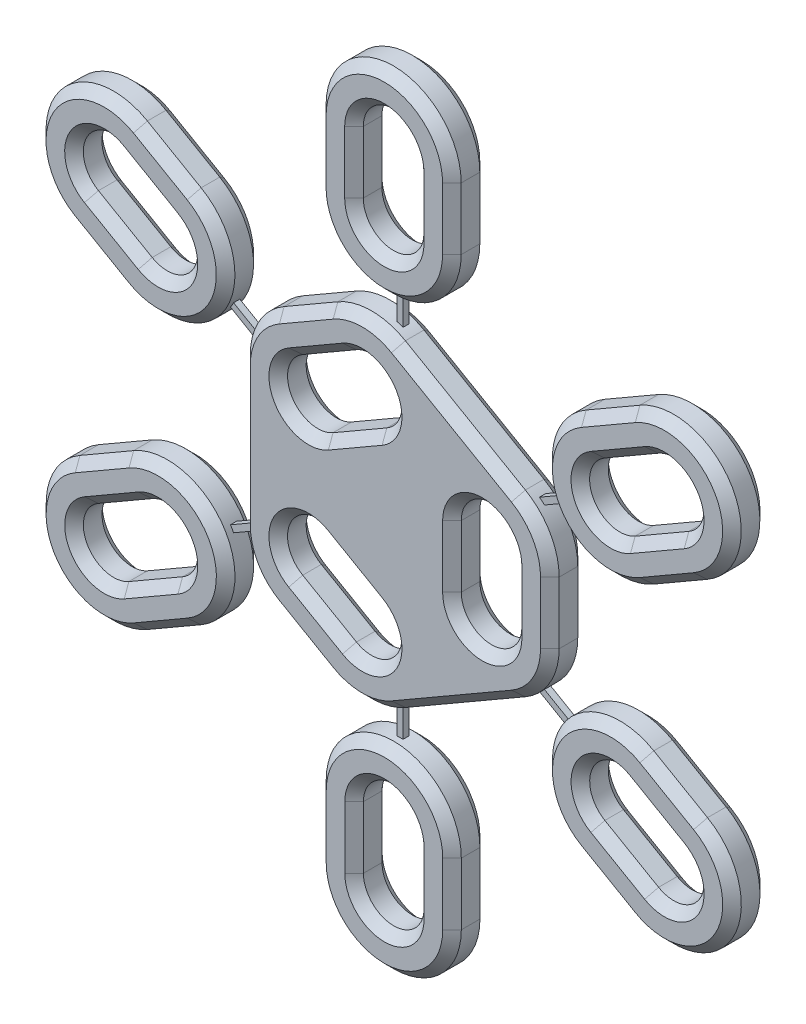
from build123d import *

# Parameters (mm, degrees)
SKETCH1_R               = 4.4
SKETCH1_R_2             = 2
BOSS_EXTRUDE1_DEPTH     = 2.4
CHAMFER1_SIZE           = 0.4
BOSS_EXTRUDE2_DEPTH     = 2.4
BOSS_EXTRUDE2_2_DEPTH   = 2.4
BOSS_EXTRUDE2_3_DEPTH   = 2.4
BOSS_EXTRUDE2_4_DEPTH   = 2.4
BOSS_EXTRUDE2_5_DEPTH   = 2.4
BOSS_EXTRUDE2_6_DEPTH   = 2.4
BOSS_EXTRUDE2_7_DEPTH   = 2.4
BOSS_EXTRUDE2_8_DEPTH   = 2.4
CHAMFER2_SIZE           = 0.6
CHAMFER3_SIZE           = 0.6
CHAMFER4_SIZE           = 0.6
CHAMFER5_SIZE           = 0.6
CHAMFER6_SIZE           = 0.6
CHAMFER7_SIZE           = 0.6
CHAMFER8_SIZE           = 0.6
CHAMFER9_SIZE           = 0.6
BOSS_EXTRUDE3_START     = -1.2
BOSS_EXTRUDE3_DEPTH     = 0.2
CIRPATTERN1_COUNT       = 6
CUT_EXTRUDE1_DEPTH      = 1
CUT_EXTRUDE1_DEPTH_BACK = 3.4


with BuildPart() as part:
    # Sketch1 → Boss-Extrude1 (new body)
    with BuildSketch(Plane.XY):
        Circle(SKETCH1_R)
        Circle(SKETCH1_R_2, mode=Mode.SUBTRACT)
    extrude(amount=BOSS_EXTRUDE1_DEPTH)

    # Chamfer1
    chamfer1_edges = [part.edges().sort_by_distance(p)[0] for p in [
        (-4.4, 0, 0),
        (-4.4, 0, 2.4),
        (-2, 0, 0),
        (-2, 0, 2.4),
    ]]
    chamfer(chamfer1_edges, length=CHAMFER1_SIZE)


with BuildPart() as body_2:
    # Sketch2 → Boss-Extrude2 (new body)
    with BuildSketch(Plane(origin=(0, 0, 0), x_dir=(-1, 0, 0), z_dir=(0, 0, -1))):
        with BuildLine():
            Line((9.243212733, 4.465626555), (9.243212733, -4.465626555))
            ThreePointArc((9.243212733, -4.465626555), (8.659675532, -6.643417036), (7.065422252, -8.237670317))
            Line((7.065422252, -8.237670317), (3.601320636, -10.237670317))
            ThreePointArc((3.601320636, -10.237670317), (1.423530155, -10.821207517), (-0.754260326, -10.237670317))
            Line((-0.754260326, -10.237670317), (-8.488952407, -5.772043762))
            ThreePointArc((-8.488952407, -5.772043762), (-10.083205687, -4.177790481), (-10.666742888, -2))
            Line((-10.666742888, -2), (-10.666742888, 2))
            ThreePointArc((-10.666742888, 2), (-10.083205687, 4.177790481), (-8.488952407, 5.772043762))
            Line((-8.488952407, 5.772043762), (-0.754260326, 10.237670317))
            ThreePointArc((-0.754260326, 10.237670317), (1.423530155, 10.821207517), (3.601320636, 10.237670317))
            Line((3.601320636, 10.237670317), (7.065422252, 8.237670317))
            ThreePointArc((7.065422252, 8.237670317), (8.659675532, 6.643417036), (9.243212733, 4.465626555))
        make_face()
        with BuildLine():
            Line((-4.355580963, 2), (-4.355580963, -2))
            ThreePointArc((-4.355580963, -2), (-6.311161925, -3.955580963), (-8.266742888, -2))
            Line((-8.266742888, -2), (-8.266742888, 2))
            ThreePointArc((-8.266742888, 2), (-6.311161925, 3.955580963), (-4.355580963, 2))
        make_face(mode=Mode.SUBTRACT)
        with BuildLine():
            Line((3.909841289, 2.772043762), (0.445739674, 4.772043762))
            ThreePointArc((0.445739674, 4.772043762), (-0.270052638, 7.443417036), (2.401320636, 8.159209348))
            Line((2.401320636, 8.159209348), (5.865422252, 6.159209348))
            ThreePointArc((5.865422252, 6.159209348), (6.581214563, 3.487836073), (3.909841289, 2.772043762))
        make_face(mode=Mode.SUBTRACT)
        with BuildLine():
            Line((0.445739674, -4.772043762), (3.909841289, -2.772043762))
            ThreePointArc((3.909841289, -2.772043762), (6.581214563, -3.487836073), (5.865422252, -6.159209348))
            Line((5.865422252, -6.159209348), (2.401320636, -8.159209348))
            ThreePointArc((2.401320636, -8.159209348), (-0.270052638, -7.443417036), (0.445739674, -4.772043762))
        make_face(mode=Mode.SUBTRACT)
    extrude(amount=BOSS_EXTRUDE2_DEPTH)

    # Chamfer3
    chamfer3_edges = [body_2.edges().sort_by_distance(p)[0] for p in [
        (-6.581214563, 3.487836073, 0),
        (-4.133371444, 7.159209348, 0),
        (0.270052638, 7.443417036, 0),
        (-2.177790481, 3.772043762, 0),
        (-6.581214563, 3.487836073, -2.4),
        (-4.133371444, 7.159209348, -2.4),
        (0.270052638, 7.443417036, -2.4),
        (-2.177790481, 3.772043762, -2.4),
        (0.270052638, -7.443417036, 0),
        (-4.133371444, -7.159209348, 0),
        (-6.581214563, -3.487836073, 0),
        (-2.177790481, -3.772043762, 0),
        (0.270052638, -7.443417036, -2.4),
        (-4.133371444, -7.159209348, -2.4),
        (-6.581214563, -3.487836073, -2.4),
        (-2.177790481, -3.772043762, -2.4),
        (6.311161925, 3.955580963, 0),
        (8.266742888, 0, 0),
        (6.311161925, -3.955580963, 0),
        (4.355580963, 0, 0),
        (6.311161925, 3.955580963, -2.4),
        (8.266742888, 0, -2.4),
        (6.311161925, -3.955580963, -2.4),
        (4.355580963, 0, -2.4),
        (10.083205687, -4.177790481, 0),
        (4.621606366, -8.004857039, 0),
        (-1.423530155, -10.821207517, 0),
        (-5.333371444, -9.237670317, 0),
        (-8.659675532, -6.643417036, 0),
        (-9.243212733, 0, 0),
        (-8.659675532, 6.643417036, 0),
        (-5.333371444, 9.237670317, 0),
        (-1.423530155, 10.821207517, 0),
        (4.621606366, 8.004857039, 0),
        (10.083205687, 4.177790481, 0),
        (10.666742888, 0, 0),
        (10.083205687, -4.177790481, -2.4),
        (4.621606366, -8.004857039, -2.4),
        (-1.423530155, -10.821207517, -2.4),
        (-5.333371444, -9.237670317, -2.4),
        (-8.659675532, -6.643417036, -2.4),
        (-9.243212733, 0, -2.4),
        (-8.659675532, 6.643417036, -2.4),
        (-5.333371444, 9.237670317, -2.4),
        (-1.423530155, 10.821207517, -2.4),
        (4.621606366, 8.004857039, -2.4),
        (10.083205687, 4.177790481, -2.4),
        (10.666742888, 0, -2.4),
    ]]
    chamfer(chamfer3_edges, length=CHAMFER3_SIZE)


with BuildPart() as body_3:
    # Sketch2 → Boss-Extrude2 2 (new body)
    with BuildSketch(Plane(origin=(0, 0, 0), x_dir=(-1, 0, 0), z_dir=(0, 0, -1))):
        with BuildLine():
            Line((4.351336317, -16.847070519), (4.351336317, -20.847070519))
            ThreePointArc((4.351336317, -20.847070519), (-0.004244646, -25.202651481), (-4.359825609, -20.847070519))
            Line((-4.359825609, -20.847070519), (-4.359825609, -16.847070519))
            ThreePointArc((-4.359825609, -16.847070519), (-0.004244646, -12.491489556), (4.351336317, -16.847070519))
        make_face()
        with BuildLine():
            Line((1.951336317, -16.847070519), (1.951336317, -20.847070519))
            ThreePointArc((1.951336317, -20.847070519), (-0.004244646, -22.802651481), (-1.959825609, -20.847070519))
            Line((-1.959825609, -20.847070519), (-1.959825609, -16.847070519))
            ThreePointArc((-1.959825609, -16.847070519), (-0.004244646, -14.891489556), (1.951336317, -16.847070519))
        make_face(mode=Mode.SUBTRACT)
    extrude(amount=BOSS_EXTRUDE2_2_DEPTH)

    # Chamfer6
    chamfer6_edges = [body_3.edges().sort_by_distance(p)[0] for p in [
        (0.004244646, -25.202651481, -2.4),
        (-4.351336317, -18.847070519, -2.4),
        (0.004244646, -14.891489556, 0),
        (1.959825609, -18.847070519, 0),
        (0.004244646, -22.802651481, 0),
        (-1.951336317, -18.847070519, -2.4),
        (0.004244646, -14.891489556, -2.4),
        (1.959825609, -18.847070519, -2.4),
        (0.004244646, -22.802651481, -2.4),
        (-1.951336317, -18.847070519, 0),
        (0.004244646, -12.491489556, -2.4),
        (-4.351336317, -18.847070519, 0),
        (0.004244646, -25.202651481, 0),
        (4.359825609, -18.847070519, 0),
        (0.004244646, -12.491489556, 0),
        (4.359825609, -18.847070519, -2.4),
    ]]
    chamfer(chamfer6_edges, length=CHAMFER6_SIZE)

    # Sketch3 → Boss-Extrude3 (add, symmetric)
    with BuildSketch(Plane(origin=(0, 0, -2.4), x_dir=(-1, 0, 0), z_dir=(0, 0, -1)).offset(BOSS_EXTRUDE3_START)):
        Polygon((0, -13.635046373), (0.2, -13.635046373), (0.2, -0.714557535), (0, 0), (-0.2, -0.714557535), (-0.2, -13.521615486), (0, -13.521615486), align=None)
    extrude(amount=BOSS_EXTRUDE3_DEPTH, both=True)


with BuildPart() as body_4:
    # Sketch2 → Boss-Extrude2 3 (new body)
    with BuildSketch(Plane(origin=(0, 0, 0), x_dir=(-1, 0, 0), z_dir=(0, 0, -1))):
        with BuildLine():
            Line((-10.458556301, -13.905988383), (-13.585882231, -16.39994759))
            ThreePointArc((-13.585882231, -16.39994759), (-19.706872863, -15.71027758), (-19.017202854, -9.589286948))
            Line((-19.017202854, -9.589286948), (-15.889876924, -7.095327741))
            ThreePointArc((-15.889876924, -7.095327741), (-9.768886291, -7.78499775), (-10.458556301, -13.905988383))
        make_face()
        with BuildLine():
            Line((-11.954931825, -12.029592825), (-15.082257755, -14.523552032))
            ThreePointArc((-15.082257755, -14.523552032), (-17.830477305, -14.213902056), (-17.520827329, -11.465682506))
            Line((-17.520827329, -11.465682506), (-14.393501399, -8.971723299))
            ThreePointArc((-14.393501399, -8.971723299), (-11.645281849, -9.281373275), (-11.954931825, -12.029592825))
        make_face(mode=Mode.SUBTRACT)
    extrude(amount=BOSS_EXTRUDE2_3_DEPTH)

    # Chamfer7
    chamfer7_edges = [body_4.edges().sort_by_distance(p)[0] for p in [
        (11.645281849, -9.281373275, 0),
        (15.957164364, -10.218702902, 0),
        (17.830477305, -14.213902056, 0),
        (13.51859479, -13.276572428, 0),
        (11.645281849, -9.281373275, -2.4),
        (15.957164364, -10.218702902, -2.4),
        (17.830477305, -14.213902056, -2.4),
        (13.51859479, -13.276572428, -2.4),
        (9.768886291, -7.78499775, 0),
        (17.453539889, -8.342307344, 0),
        (19.706872863, -15.71027758, 0),
        (12.022219266, -15.152967986, 0),
        (9.768886291, -7.78499775, -2.4),
        (17.453539889, -8.342307344, -2.4),
        (19.706872863, -15.71027758, -2.4),
        (12.022219266, -15.152967986, -2.4),
    ]]
    chamfer(chamfer7_edges, length=CHAMFER7_SIZE)


with BuildPart() as body_5:
    # Sketch2 → Boss-Extrude2 4 (new body)
    with BuildSketch(Plane(origin=(0, 0, 0), x_dir=(-1, 0, 0), z_dir=(0, 0, -1))):
        with BuildLine():
            Line((-17.392942708, -0.493413364), (-21.292654357, 0.396670372))
            ThreePointArc((-21.292654357, 0.396670372), (-24.569823868, 5.61225577), (-19.35423847, 8.88942528))
            Line((-19.35423847, 8.88942528), (-15.454526821, 7.999341544))
            ThreePointArc((-15.454526821, 7.999341544), (-12.17735731, 2.783756146), (-17.392942708, -0.493413364))
        make_face()
        with BuildLine():
            Line((-16.858892467, 1.846413625), (-20.758604116, 2.736497361))
            ThreePointArc((-20.758604116, 2.736497361), (-22.229996878, 5.078205528), (-19.888288711, 6.549598291))
            Line((-19.888288711, 6.549598291), (-15.988577062, 5.659514555))
            ThreePointArc((-15.988577062, 5.659514555), (-14.5171843, 3.317806388), (-16.858892467, 1.846413625))
        make_face(mode=Mode.SUBTRACT)
    extrude(amount=BOSS_EXTRUDE2_4_DEPTH)

    # Chamfer8
    chamfer8_edges = [body_5.edges().sort_by_distance(p)[0] for p in [
        (14.5171843, 3.317806388, 0),
        (17.938432887, 6.104556423, 0),
        (22.229996878, 5.078205528, 0),
        (18.808748291, 2.291455493, 0),
        (14.5171843, 3.317806388, -2.4),
        (17.938432887, 6.104556423, -2.4),
        (22.229996878, 5.078205528, -2.4),
        (18.808748291, 2.291455493, -2.4),
        (12.17735731, 2.783756146, 0),
        (17.404382645, 8.444383412, 0),
        (24.569823868, 5.61225577, 0),
        (19.342798533, -0.048371496, 0),
        (12.17735731, 2.783756146, -2.4),
        (17.404382645, 8.444383412, -2.4),
        (24.569823868, 5.61225577, -2.4),
        (19.342798533, -0.048371496, -2.4),
    ]]
    chamfer(chamfer8_edges, length=CHAMFER8_SIZE)


with BuildPart() as body_6:
    # Sketch2 → Boss-Extrude2 5 (new body)
    with BuildSketch(Plane(origin=(0, 0, 0), x_dir=(-1, 0, 0), z_dir=(0, 0, -1))):
        with BuildLine():
            Line((-11.230088505, 13.290711982), (-12.965623461, 16.894587453))
            ThreePointArc((-12.965623461, 16.894587453), (-10.931196366, 22.708646056), (-5.117137763, 20.674218961))
            Line((-5.117137763, 20.674218961), (-3.381602807, 17.07034349))
            ThreePointArc((-3.381602807, 17.07034349), (-5.416029902, 11.256284887), (-11.230088505, 13.290711982))
        make_face()
        with BuildLine():
            Line((-9.067763222, 14.332032955), (-10.803298178, 17.935908427))
            ThreePointArc((-10.803298178, 17.935908427), (-9.889875393, 20.546320773), (-7.279463046, 19.632897987))
            Line((-7.279463046, 19.632897987), (-5.54392809, 16.029022516))
            ThreePointArc((-5.54392809, 16.029022516), (-6.457350876, 13.41861017), (-9.067763222, 14.332032955))
        make_face(mode=Mode.SUBTRACT)
    extrude(amount=BOSS_EXTRUDE2_5_DEPTH)

    # Chamfer9
    chamfer9_edges = [body_6.edges().sort_by_distance(p)[0] for p in [
        (6.457350876, 13.41861017, 0),
        (6.411695568, 17.830960252, 0),
        (9.889875393, 20.546320773, 0),
        (9.9355307, 16.133970691, 0),
        (6.457350876, 13.41861017, -2.4),
        (6.411695568, 17.830960252, -2.4),
        (9.889875393, 20.546320773, -2.4),
        (9.9355307, 16.133970691, -2.4),
        (5.416029902, 11.256284887, 0),
        (4.249370285, 18.872281226, 0),
        (10.931196366, 22.708646056, 0),
        (12.097855983, 15.092649717, 0),
        (5.416029902, 11.256284887, -2.4),
        (4.249370285, 18.872281226, -2.4),
        (10.931196366, 22.708646056, -2.4),
        (12.097855983, 15.092649717, -2.4),
    ]]
    chamfer(chamfer9_edges, length=CHAMFER9_SIZE)


with BuildPart() as body_7:
    # Sketch2 → Boss-Extrude2 6 (new body)
    with BuildSketch(Plane(origin=(0, 0, 0), x_dir=(-1, 0, 0), z_dir=(0, 0, -1))):
        with BuildLine():
            Line((3.389251395, 17.066660124), (5.124786351, 20.670535595))
            ThreePointArc((5.124786351, 20.670535595), (10.938844954, 22.70496269), (12.973272049, 16.890904087))
            Line((12.973272049, 16.890904087), (11.237737093, 13.287028616))
            ThreePointArc((11.237737093, 13.287028616), (5.42367849, 11.252601521), (3.389251395, 17.066660124))
        make_face()
        with BuildLine():
            Line((5.551576678, 16.02533915), (7.287111634, 19.629214622))
            ThreePointArc((7.287111634, 19.629214622), (9.897523981, 20.542637407), (10.810946766, 17.932225061))
            Line((10.810946766, 17.932225061), (9.07541181, 14.32834959))
            ThreePointArc((9.07541181, 14.32834959), (6.464999464, 13.414926804), (5.551576678, 16.02533915))
        make_face(mode=Mode.SUBTRACT)
    extrude(amount=BOSS_EXTRUDE2_6_DEPTH)

    # Chamfer4
    chamfer4_edges = [body_7.edges().sort_by_distance(p)[0] for p in [
        (-6.464999464, 13.414926804, 0),
        (-9.943179288, 16.130287325, 0),
        (-9.897523981, 20.542637407, 0),
        (-6.419344156, 17.827276886, 0),
        (-6.464999464, 13.414926804, -2.4),
        (-9.943179288, 16.130287325, -2.4),
        (-9.897523981, 20.542637407, -2.4),
        (-6.419344156, 17.827276886, -2.4),
        (-5.42367849, 11.252601521, 0),
        (-12.105504571, 15.088966351, 0),
        (-10.938844954, 22.70496269, 0),
        (-4.257018873, 18.86859786, 0),
        (-5.42367849, 11.252601521, -2.4),
        (-12.105504571, 15.088966351, -2.4),
        (-10.938844954, 22.70496269, -2.4),
        (-4.257018873, 18.86859786, -2.4),
    ]]
    chamfer(chamfer4_edges, length=CHAMFER4_SIZE)


with BuildPart() as body_8:
    # Sketch2 → Boss-Extrude2 7 (new body)
    with BuildSketch(Plane(origin=(0, 0, 0), x_dir=(-1, 0, 0), z_dir=(0, 0, -1))):
        with BuildLine():
            Line((15.456415866, 7.991065097), (19.356127515, 8.881148832))
            ThreePointArc((19.356127515, 8.881148832), (24.571712913, 5.603979322), (21.294543402, 0.388393924))
            Line((21.294543402, 0.388393924), (17.394831754, -0.501689812))
            ThreePointArc((17.394831754, -0.501689812), (12.179246356, 2.775479699), (15.456415866, 7.991065097))
        make_face()
        with BuildLine():
            Line((15.990466108, 5.651238107), (19.890177756, 6.541321843))
            ThreePointArc((19.890177756, 6.541321843), (22.231885924, 5.06992908), (20.760493161, 2.728220913))
            Line((20.760493161, 2.728220913), (16.860781512, 1.838137177))
            ThreePointArc((16.860781512, 1.838137177), (14.519073345, 3.30952994), (15.990466108, 5.651238107))
        make_face(mode=Mode.SUBTRACT)
    extrude(amount=BOSS_EXTRUDE2_7_DEPTH)

    # Chamfer2
    chamfer2_edges = [body_8.edges().sort_by_distance(p)[0] for p in [
        (-14.519073345, 3.30952994, 0),
        (-18.810637336, 2.283179045, 0),
        (-22.231885924, 5.06992908, 0),
        (-17.940321932, 6.096279975, 0),
        (-14.519073345, 3.30952994, -2.4),
        (-18.810637336, 2.283179045, -2.4),
        (-22.231885924, 5.06992908, -2.4),
        (-17.940321932, 6.096279975, -2.4),
        (-12.179246356, 2.775479699, 0),
        (-19.344687578, -0.056647944, 0),
        (-24.571712913, 5.603979322, 0),
        (-17.40627169, 8.436106964, 0),
        (-12.179246356, 2.775479699, -2.4),
        (-19.344687578, -0.056647944, -2.4),
        (-24.571712913, 5.603979322, -2.4),
        (-17.40627169, 8.436106964, -2.4),
    ]]
    chamfer(chamfer2_edges, length=CHAMFER2_SIZE)


with BuildPart() as body_9:
    # Sketch2 → Boss-Extrude2 8 (new body)
    with BuildSketch(Plane(origin=(0, 0, 0), x_dir=(-1, 0, 0), z_dir=(0, 0, -1))):
        with BuildLine():
            Line((15.884583937, -7.101964936), (19.011909867, -9.595924144))
            ThreePointArc((19.011909867, -9.595924144), (19.701579876, -15.716914776), (13.580589244, -16.406584786))
            Line((13.580589244, -16.406584786), (10.453263314, -13.912625579))
            ThreePointArc((10.453263314, -13.912625579), (9.763593304, -7.791634946), (15.884583937, -7.101964936))
        make_face()
        with BuildLine():
            Line((14.388208412, -8.978360494), (17.515534342, -11.472319702))
            ThreePointArc((17.515534342, -11.472319702), (17.825184318, -14.220539252), (15.076964768, -14.530189228))
            Line((15.076964768, -14.530189228), (11.949638838, -12.036230021))
            ThreePointArc((11.949638838, -12.036230021), (11.639988862, -9.288010471), (14.388208412, -8.978360494))
        make_face(mode=Mode.SUBTRACT)
    extrude(amount=BOSS_EXTRUDE2_8_DEPTH)

    # Chamfer5
    chamfer5_edges = [body_9.edges().sort_by_distance(p)[0] for p in [
        (-11.639988862, -9.288010471, 0),
        (-13.513301803, -13.283209624, 0),
        (-17.825184318, -14.220539252, 0),
        (-15.951871377, -10.225340098, 0),
        (-11.639988862, -9.288010471, -2.4),
        (-13.513301803, -13.283209624, -2.4),
        (-17.825184318, -14.220539252, -2.4),
        (-15.951871377, -10.225340098, -2.4),
        (-9.763593304, -7.791634946, 0),
        (-12.016926279, -15.159605182, 0),
        (-19.701579876, -15.716914776, 0),
        (-17.448246902, -8.34894454, 0),
        (-9.763593304, -7.791634946, -2.4),
        (-12.016926279, -15.159605182, -2.4),
        (-19.701579876, -15.716914776, -2.4),
        (-17.448246902, -8.34894454, -2.4),
    ]]
    chamfer(chamfer5_edges, length=CHAMFER5_SIZE)


with BuildPart() as cirpattern1_1:
    # CirPattern1: pattern copy
    add(body_3.part.rotate(Axis((0, 0, 0), (0, 0, 1)), 1 * 360 / CIRPATTERN1_COUNT))


with BuildPart() as cirpattern1_2:
    # CirPattern1: pattern copy
    add(body_3.part.rotate(Axis((0, 0, 0), (0, 0, 1)), 2 * 360 / CIRPATTERN1_COUNT))


with BuildPart() as cirpattern1_3:
    # CirPattern1: pattern copy
    add(body_3.part.rotate(Axis((0, 0, 0), (0, 0, 1)), 3 * 360 / CIRPATTERN1_COUNT))


with BuildPart() as cirpattern1_4:
    # CirPattern1: pattern copy
    add(body_3.part.rotate(Axis((0, 0, 0), (0, 0, 1)), 4 * 360 / CIRPATTERN1_COUNT))


with BuildPart() as cirpattern1_5:
    # CirPattern1: pattern copy
    add(body_3.part.rotate(Axis((0, 0, 0), (0, 0, 1)), 5 * 360 / CIRPATTERN1_COUNT))


with BuildPart() as cut_extrude1_tool:
    # Sketch4 → Cut-Extrude1 (new body, two sides)
    with BuildSketch(Plane(origin=(0, 0, -2.4), x_dir=(-1, 0, 0), z_dir=(0, 0, -1))) as cut_extrude1_sk:
        with BuildLine():
            Line((-10.066742888, 2), (-10.066742888, -2))
            ThreePointArc((-10.066742888, -2), (-9.563590445, -3.877790481), (-8.188952407, -5.25242852))
            Line((-8.188952407, -5.25242852), (-0.454260326, -9.718055074))
            ThreePointArc((-0.454260326, -9.718055074), (1.423530155, -10.221207517), (3.301320636, -9.718055074))
            Line((3.301320636, -9.718055074), (6.765422252, -7.718055074))
            ThreePointArc((6.765422252, -7.718055074), (8.14006029, -6.343417036), (8.643212733, -4.465626555))
            Line((8.643212733, -4.465626555), (8.643212733, 4.465626555))
            ThreePointArc((8.643212733, 4.465626555), (8.14006029, 6.343417036), (6.765422252, 7.718055074))
            Line((6.765422252, 7.718055074), (3.301320636, 9.718055074))
            ThreePointArc((3.301320636, 9.718055074), (1.423530155, 10.221207517), (-0.454260326, 9.718055074))
            Line((-0.454260326, 9.718055074), (-8.188952407, 5.25242852))
            ThreePointArc((-8.188952407, 5.25242852), (-9.563590445, 3.877790481), (-10.066742888, 2))
        make_face()
    extrude(amount=CUT_EXTRUDE1_DEPTH)
    extrude(cut_extrude1_sk.sketch, amount=-CUT_EXTRUDE1_DEPTH_BACK)


with BuildPart() as body_3_1:
    add(body_3.part)

    # Cut-Extrude1: cut by cut_extrude1_tool
    add(cut_extrude1_tool.part, mode=Mode.SUBTRACT)


with BuildPart() as cirpattern1_1_1:
    add(cirpattern1_1.part)

    # Cut-Extrude1: cut by cut_extrude1_tool
    add(cut_extrude1_tool.part, mode=Mode.SUBTRACT)


with BuildPart() as cirpattern1_2_1:
    add(cirpattern1_2.part)

    # Cut-Extrude1: cut by cut_extrude1_tool
    add(cut_extrude1_tool.part, mode=Mode.SUBTRACT)


with BuildPart() as cirpattern1_3_1:
    add(cirpattern1_3.part)

    # Cut-Extrude1: cut by cut_extrude1_tool
    add(cut_extrude1_tool.part, mode=Mode.SUBTRACT)


with BuildPart() as cirpattern1_4_1:
    add(cirpattern1_4.part)

    # Cut-Extrude1: cut by cut_extrude1_tool
    add(cut_extrude1_tool.part, mode=Mode.SUBTRACT)


with BuildPart() as cirpattern1_5_1:
    add(cirpattern1_5.part)

    # Cut-Extrude1: cut by cut_extrude1_tool
    add(cut_extrude1_tool.part, mode=Mode.SUBTRACT)


with BuildPart() as cirpattern1_4_2:
    add(cirpattern1_4_1.part)

    # Combine1: union CirPattern1_1, body 2, CirPattern1_3, CirPattern1_5, CirPattern1_2, body 3
    add(cirpattern1_1_1.part)
    add(body_2.part)
    add(cirpattern1_3_1.part)
    add(cirpattern1_5_1.part)
    add(cirpattern1_2_1.part)
    add(body_3_1.part)


solid = cirpattern1_4_2.part
